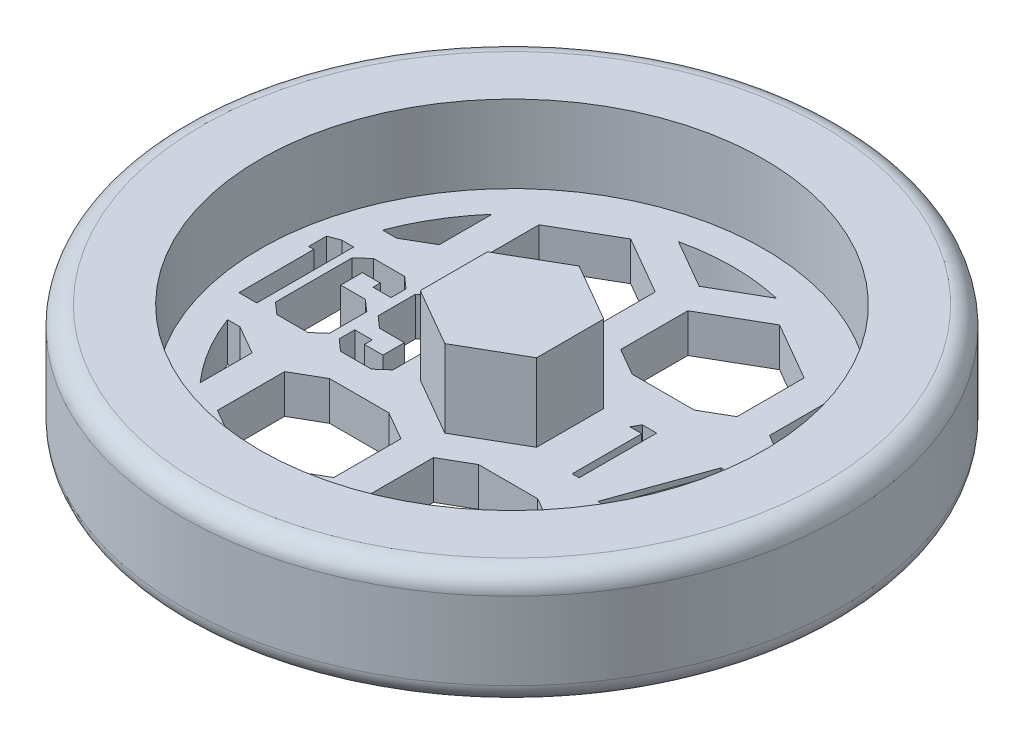
from build123d import *

# Parameters (mm, degrees)
BOSS_EXTRUDE1_DEPTH     = 6.35
CUT_EXTRUDE1_DEPTH      = 7.35
CUT_EXTRUDE1_DEPTH_BACK = 4.175
CUT_EXTRUDE2_DEPTH      = 7.35
CUT_EXTRUDE2_DEPTH_BACK = 4.175


with BuildPart() as part:
    # Sketch1 → Revolve1 (revolve)
    with BuildSketch(Plane.XY):
        with BuildLine():
            Line((0, 0), (25.4, 0))
            ThreePointArc((25.4, 0), (26.522532015, 0.464967985), (26.9875, 1.5875))
            Line((26.9875, 1.5875), (26.9875, 7.9375))
            ThreePointArc((26.9875, 7.9375), (26.522532015, 9.060032015), (25.4, 9.525))
            Line((25.4, 9.525), (20.6375, 9.525))
            Line((20.6375, 9.525), (20.6375, 3.175))
            Line((20.6375, 3.175), (0, 3.175))
            Line((0, 3.175), (0, 0))
        make_face()
    revolve(axis=Axis((0, 3.175, 0), (0, -1, 0)))

    # Sketch2 → Boss-Extrude1 (add)
    with BuildSketch(Plane(origin=(0, 3.175, 0), x_dir=(1, 0, 0), z_dir=(0, 1, 0))):
        Polygon((0, 5.499261314), (-4.7625, 2.749630657), (-4.7625, -2.749630657), (0, -5.499261314), (4.7625, -2.749630657), (4.7625, 2.749630657), align=None)
    extrude(amount=BOSS_EXTRUDE1_DEPTH)

    # Sketch3 → Cut-Extrude1 (cut, two sides)
    with BuildSketch(Plane(origin=(0, 3.175, 0), x_dir=(1, 0, 0), z_dir=(0, 1, 0))) as cut_extrude1_sk:
        Polygon((-6.60689834, -3.139369578), (-7.545565353, -3.96875), (-10.072630611, -3.96875), (-11.0127947, -3.139369578), (-11.0127947, -1.862363259), (-9.583086571, -1.862363259), (-9.583086571, -2.503112033), (-8.07103923, -2.503112033), (-8.07103923, -0.735064598), (-10.117542908, -0.735064598), (-11.053215768, 0.094315824), (-11.053215768, 3.134878348), (-10.117542908, 3.96875), (-7.556044889, 3.96875), (-6.60689834, 3.130387118), align=None)
        Polygon((-11.800256978, -3.139369578), (-12.740421068, -3.96875), (-15.286948321, -3.96875), (-16.22711241, -3.139369578), (-16.22711241, 3.134878348), (-15.297427857, 3.96875), (-12.755391833, 3.96875), (-11.815227744, 3.134878348), (-11.815227744, 1.907275556), (-13.285356941, 1.907275556), (-13.285356941, 2.503112033), (-14.761474444, 2.503112033), (-14.761474444, 0.735064598), (-12.740421068, 0.735064598), (-11.800256978, -0.088327518), align=None)
        Polygon((-16.929241324, -3.96875), (-18.394879291, -3.96875), (-18.394879291, 2.164772727), (-18.814060732, 2.164772727), (-18.814060732, 3.630410694), (-17.909826481, 3.96875), (-16.929241324, 3.96875), align=None)
        Polygon((7.496103766, 3.175), (8.670192308, 3.175), (8.670192308, -3.175), (8.100320513, -3.175), (8.100320513, 2.523717949), (7.123397436, 2.523717949), align=None)
        Polygon((14.368910256, 3.337820513), (11.712900641, -4.070512821), (11.1125, -4.070512821), (13.768509615, 3.337820513), align=None)
        Polygon((18.323667869, 3.337820513), (18.439423077, 3.337820513), (18.439423077, -1.058333333), (19.172115385, -1.058333333), (19.172115385, -1.709615385), (18.439423077, -1.709615385), (18.439423077, -3.175), (17.869551282, -3.175), (17.869551282, -1.709615385), (14.857371795, -1.709615385), align=None)
        Polygon((17.869551282, -1.058333333), (17.869551282, 1.699439103), (15.976762821, -1.058333333), align=None, mode=Mode.SUBTRACT)
    extrude(amount=CUT_EXTRUDE1_DEPTH, mode=Mode.SUBTRACT)
    extrude(cut_extrude1_sk.sketch, amount=-CUT_EXTRUDE1_DEPTH_BACK, mode=Mode.SUBTRACT)

    # Sketch4 → Cut-Extrude2 (cut, two sides)
    with BuildSketch(Plane(origin=(0, 3.175, 0), x_dir=(1, 0, 0), z_dir=(0, 1, 0))) as cut_extrude2_sk:
        with BuildLine():
            Line((-16.946887804, 6.35), (-15.805631592, 6.35))
            Line((-15.805631592, 6.35), (-13.589, 7.629772846))
            Line((-13.589, 7.629772846), (-13.589, 11.952346433))
            ThreePointArc((-13.589, 11.952346433), (-15.522779467, 9.303914438), (-16.946887804, 6.35))
        make_face()
        Polygon((-8.705368408, 6.35), (-3.613631592, 6.35), (-1.397, 7.629772846), (-1.397, 13.12903416), (-6.1595, 15.878664817), (-10.922, 13.12903416), (-10.922, 7.629772846), align=None)
        with BuildLine():
            ThreePointArc((4.014638475, 17.64659129), (0, 18.0975), (-4.014638475, 17.64659129))
            Line((-4.014638475, 17.64659129), (0, 15.328738686))
            Line((0, 15.328738686), (4.014638475, 17.64659129))
        make_face()
        Polygon((1.27, 7.629772846), (3.486631592, 6.35), (8.578368408, 6.35), (10.795, 7.629772846), (10.795, 13.12903416), (6.0325, 15.878664817), (1.27, 13.12903416), align=None)
        with BuildLine():
            Line((13.462, 7.629772846), (15.678631592, 6.35))
            Line((15.678631592, 6.35), (16.946887804, 6.35))
            ThreePointArc((16.946887804, 6.35), (15.473427829, 9.385762487), (13.462, 12.095208235))
            Line((13.462, 12.095208235), (13.462, 7.629772846))
        make_face()
        Polygon((8.458522628, -6.35), (3.606477372, -6.35), (1.27, -7.69896584), (1.27, -13.198227154), (6.0325, -15.947857811), (10.795, -13.198227154), (10.795, -7.69896584), align=None)
        with BuildLine():
            Line((16.946887804, -6.35), (15.798477372, -6.35))
            Line((15.798477372, -6.35), (13.462, -7.69896584))
            Line((13.462, -7.69896584), (13.462, -12.095208235))
            ThreePointArc((13.462, -12.095208235), (15.473427829, -9.385762487), (16.946887804, -6.35))
        make_face()
        with BuildLine():
            Line((0, -15.328738686), (-4.014638475, -17.64659129))
            ThreePointArc((-4.014638475, -17.64659129), (0, -18.0975), (4.014638475, -17.64659129))
            Line((4.014638475, -17.64659129), (0, -15.328738686))
        make_face()
        Polygon((-1.397, -7.69896584), (-3.733477372, -6.35), (-8.585522628, -6.35), (-10.922, -7.69896584), (-10.922, -13.198227154), (-6.1595, -15.947857811), (-1.397, -13.198227154), align=None)
        with BuildLine():
            Line((-13.589, -7.69896584), (-15.925477372, -6.35))
            Line((-15.925477372, -6.35), (-16.946887804, -6.35))
            ThreePointArc((-16.946887804, -6.35), (-15.522779467, -9.303914438), (-13.589, -11.952346433))
            Line((-13.589, -11.952346433), (-13.589, -7.69896584))
        make_face()
    extrude(amount=CUT_EXTRUDE2_DEPTH, mode=Mode.SUBTRACT)
    extrude(cut_extrude2_sk.sketch, amount=-CUT_EXTRUDE2_DEPTH_BACK, mode=Mode.SUBTRACT)


solid = part.part
